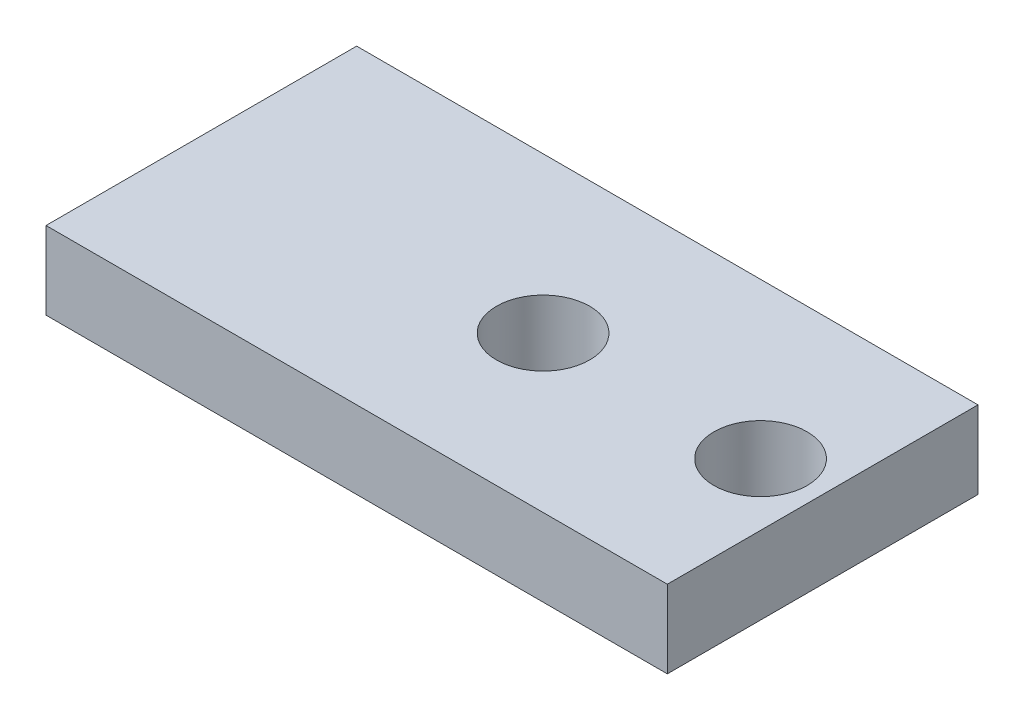
from build123d import *

# Parameters (mm, degrees)
SKETCH_1_W      = 40
SKETCH_1_H      = 20
EXTRUDE_1_DEPTH = 5
MM_3_D          = 6
MM_3_DEPTH      = 20
MM_3_TIP        = 1.802581857


with BuildPart() as part:
    # 草图1 → 凸台-拉伸1 (new body)
    with BuildSketch(Plane(origin=(0, 0, 0), x_dir=(1, 0, 0), z_dir=(0, 1, 0))):
        Rectangle(SKETCH_1_W, SKETCH_1_H)
    extrude(amount=EXTRUDE_1_DEPTH)

    # 大小mm 暗销槽口3
    with Locations(Plane(origin=(16, 0, 0), x_dir=(0, 0, -1), z_dir=(0, -1, 0))):
        with Locations((0, 0), (0, -14)):
            Hole(MM_3_D / 2, depth=MM_3_DEPTH)
            with Locations((0, 0, -(MM_3_DEPTH + MM_3_TIP / 2))):  # 118° drill point
                Cone(0, MM_3_D / 2, MM_3_TIP, mode=Mode.SUBTRACT)


solid = part.part
